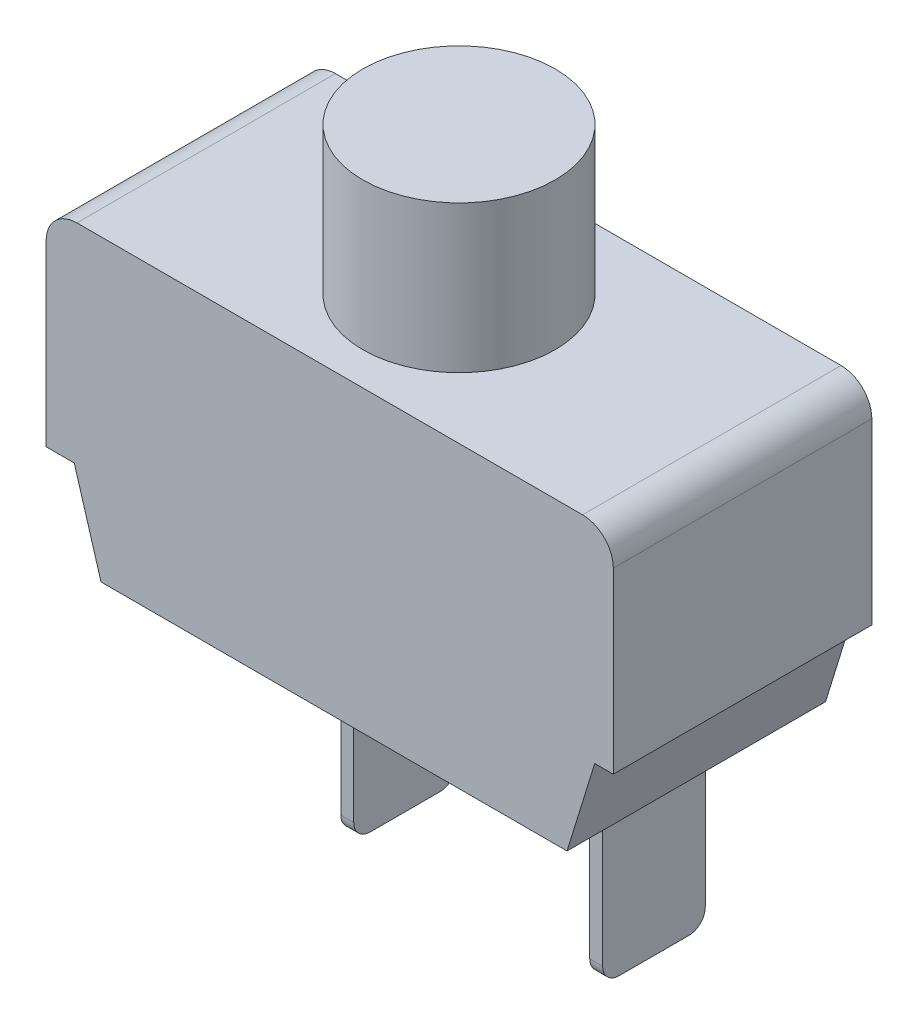
from build123d import *

# Parameters (mm, degrees)
BOSS_EXTRUDE1_DEPTH = 8
FILLET1_R           = 1.905
SKETCH2_R           = 5.953125
BOSS_EXTRUDE2_DEPTH = 9.1
SKETCH1_4_W         = 0.8
SKETCH1_4_H         = 10.916687254
EXTRUDE_THIN1_DEPTH = 3.175
FILLET2_R           = 1.016


with BuildPart() as part:
    # Sketch1 → Boss-Extrude1 (new, symmetric)
    with BuildSketch(Plane.XY):
        Polygon((-17.55, 0), (-17.55, -12.953853844), (-15.810469007, -12.953853844), (-14.154511139, -18.5), (-3.740094375, -18.5), (11.66595999, -18.5), (14.686720063, -18.5), (16.396875628, -12.953853844), (17.55, -12.953853844), (17.55, 0), align=None)
    extrude(amount=BOSS_EXTRUDE1_DEPTH, both=True)

    # Fillet1
    fillet1_edges = [part.edges().sort_by_distance(p)[0] for p in [
        (-17.55, 0, 0),
        (17.55, 0, 0),
    ]]
    fillet(fillet1_edges, radius=FILLET1_R)

    # Sketch2 → Boss-Extrude2 (add)
    with BuildSketch(Plane(origin=(0, 0, 0), x_dir=(1, 0, 0), z_dir=(0, 1, 0))):
        Circle(SKETCH2_R)
    extrude(amount=BOSS_EXTRUDE2_DEPTH)

    # Sketch1_4 → Extrude-Thin1 (add, symmetric)
    with BuildSketch(Plane.XY):
        with Locations((-3.740094375, -23.958343627)):
            Rectangle(SKETCH1_4_W, SKETCH1_4_H)
        with Locations((11.66595999, -23.958343627)):
            Rectangle(SKETCH1_4_W, SKETCH1_4_H)
    extrude(amount=EXTRUDE_THIN1_DEPTH, both=True)

    # Fillet2
    fillet2_edges = [part.edges().sort_by_distance(p)[0] for p in [
        (-3.740094375, -29.416687254, -3.175),
        (11.66595999, -29.416687254, -3.175),
        (-3.740094375, -29.416687254, 3.175),
        (11.66595999, -29.416687254, 3.175),
    ]]
    fillet(fillet2_edges, radius=FILLET2_R)


solid = part.part
